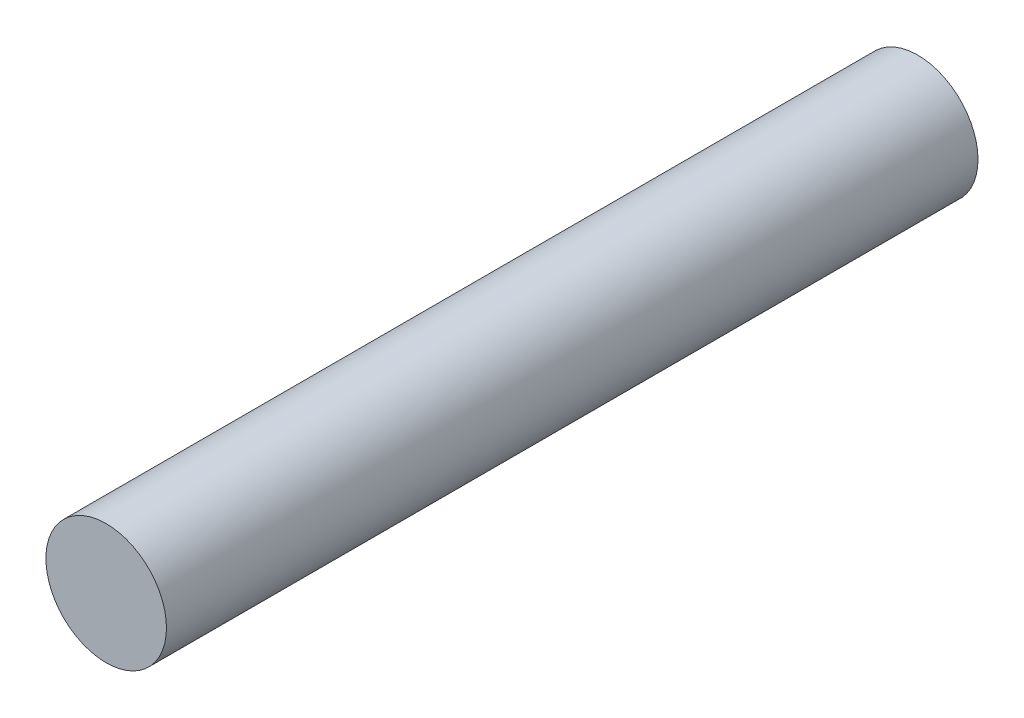
from build123d import *

# Parameters (mm, degrees)
SKETCH1_R      = 3.302
EXTRUDE1_DEPTH = 44.45


with BuildPart() as part:
    # Sketch1 → Extrude1 (new body)
    with BuildSketch(Plane.XY):
        Circle(SKETCH1_R)
    extrude(amount=EXTRUDE1_DEPTH)


solid = part.part
